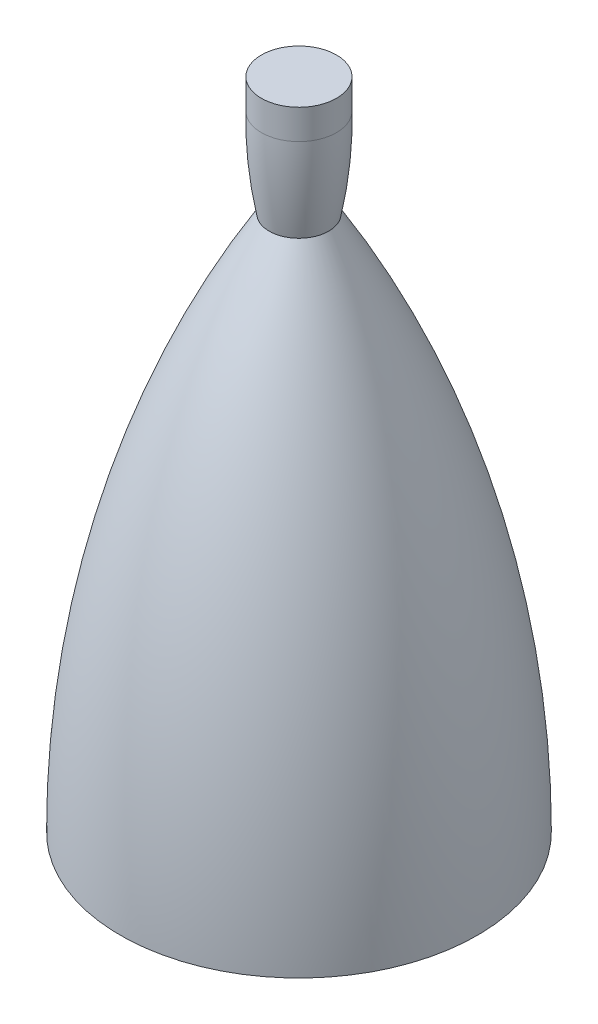
from build123d import *


with BuildPart() as part:
    # Sketch1 → Revolve1 (revolve)
    with BuildSketch(Plane.XY):
        with BuildLine():
            Line((0, 0), (152.4, 0))
            ThreePointArc((152.4, 0), (120.135787723, 237.276607701), (25.4, 457.2))
            ThreePointArc((25.4, 457.2), (30.708407126, 495.127077831), (32.059646447, 533.4))
            Line((32.059646447, 533.4), (32.059646447, 558.8))
            Line((32.059646447, 558.8), (0, 558.8))
            Line((0, 558.8), (0, 533.4))
            Line((0, 533.4), (0, 457.2))
            Line((0, 457.2), (0, 0))
        make_face()
    revolve(axis=Axis((0, 0, 0), (0, 1, 0)))


solid = part.part
